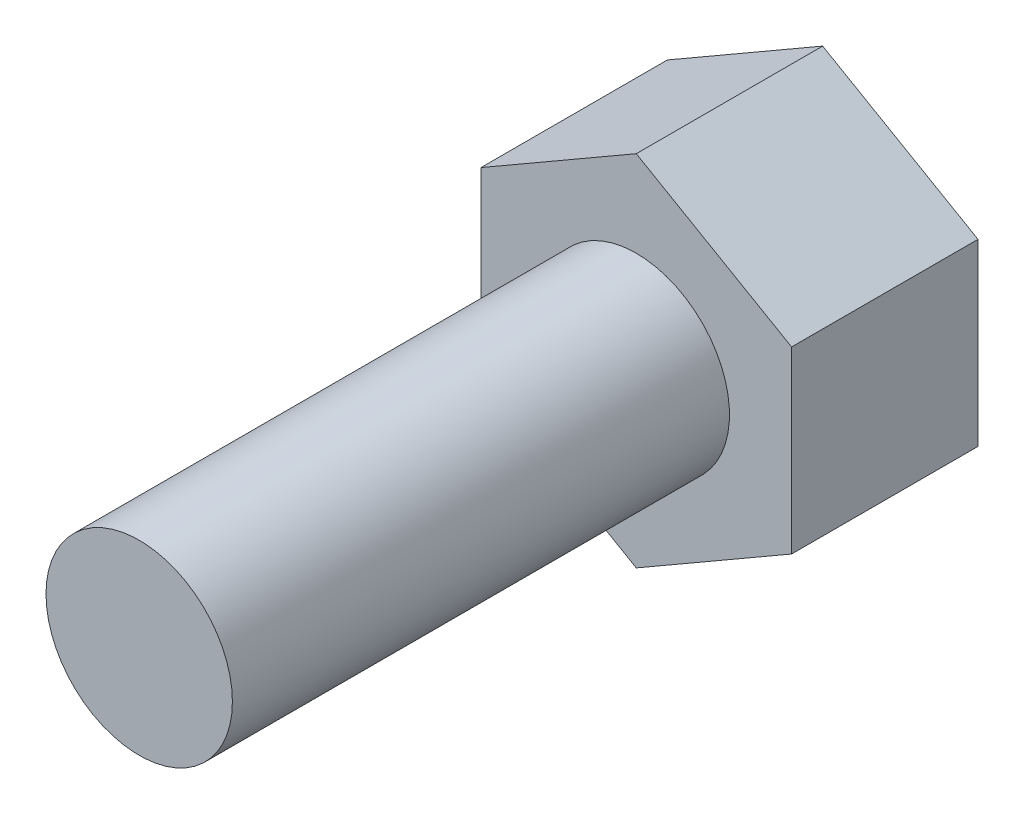
from build123d import *

# Parameters (mm, degrees)
SKETCH1_R           = 1.5
BOSS_EXTRUDE1_DEPTH = 8
BOSS_EXTRUDE2_DEPTH = 3


with BuildPart() as part:
    # Sketch1 → Boss-Extrude1 (new body)
    with BuildSketch(Plane.XY):
        with Locations((-63.49476159, 14.978708134)):
            Circle(SKETCH1_R)
    extrude(amount=BOSS_EXTRUDE1_DEPTH)

    # Sketch2 → Boss-Extrude2 (add)
    with BuildSketch(Plane(origin=(0, 0, 0), x_dir=(-1, 0, 0), z_dir=(0, 0, -1))):
        Polygon((63.49476159, 12.091956788), (65.99476159, 13.535332461), (65.99476159, 16.422083807), (63.49476159, 17.86545948), (60.99476159, 16.422083807), (60.99476159, 13.535332461), align=None)
    extrude(amount=BOSS_EXTRUDE2_DEPTH)


solid = part.part
